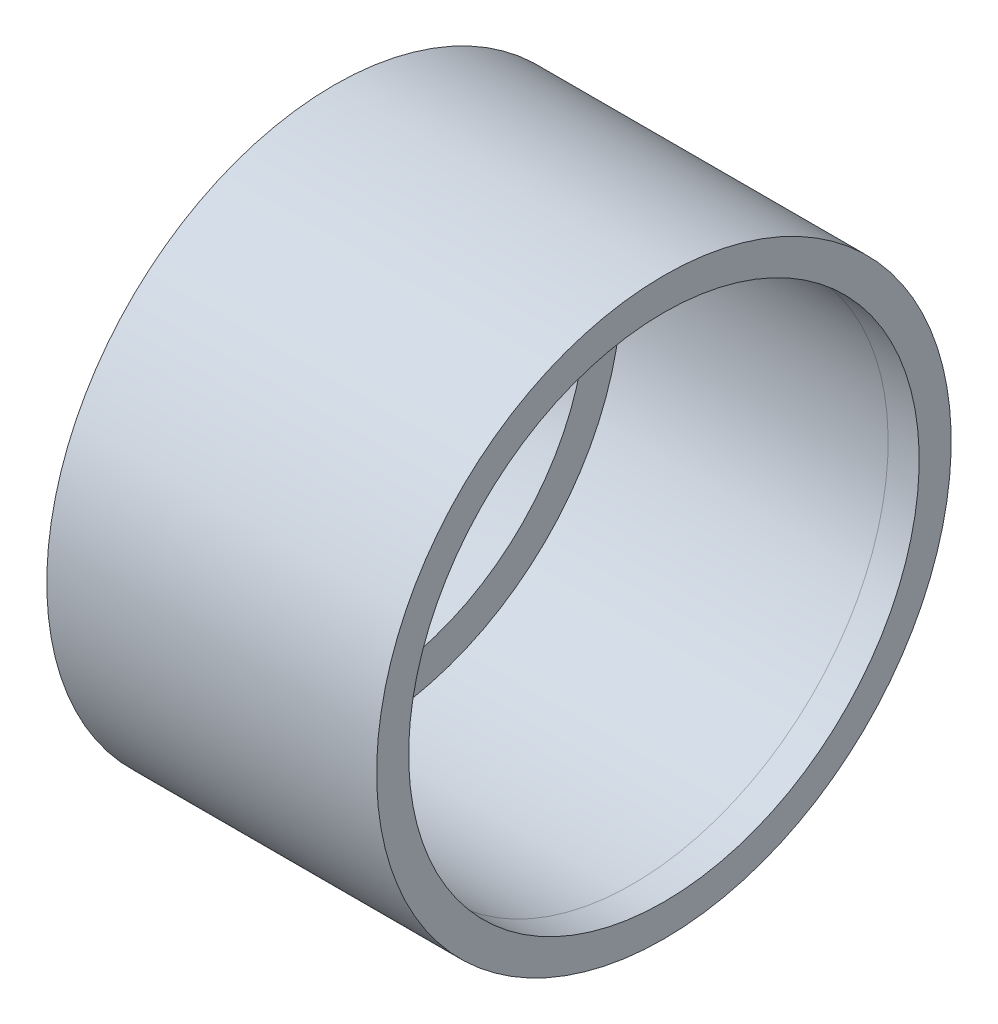
from build123d import *


with BuildPart() as part:
    # Sketch2 → Revolve1 (revolve)
    with BuildSketch(Plane.XY):
        Polygon((-18.916428128, 0), (-18.916428128, -13.404553802), (-18.916428128, -18.218989764), (0, -18.218989764), (2, -18.218989764), (2, 0), (0, 0), (0, -16.217989764), (0, -16.218989764), (-16.916428128, -16.218989764), (-16.916428128, 0), align=None)
    revolve(axis=Axis((-16.916428128, 0, 0), (-1, 0, 0)))

    # Sketch5 → Cut-Revolve2 (revolve, cut)
    with BuildSketch(Plane.XY):
        with BuildLine():
            Line((-18.916428128, 0), (-18.916428128, -13.404553802))
            Line((-18.916428128, -13.404553802), (-18.916428128, -13.405553802))
            ThreePointArc((-18.916428128, -13.405553802), (-8.571883314, -15.651301661), (2, -16.188213247))
            Line((2, -16.188213247), (2, 0))
            Line((2, 0), (-18.916428128, 0))
        make_face()
    revolve(axis=Axis((-18.916428128, 0, 0), (1, 0, 0)), mode=Mode.SUBTRACT)


solid = part.part
